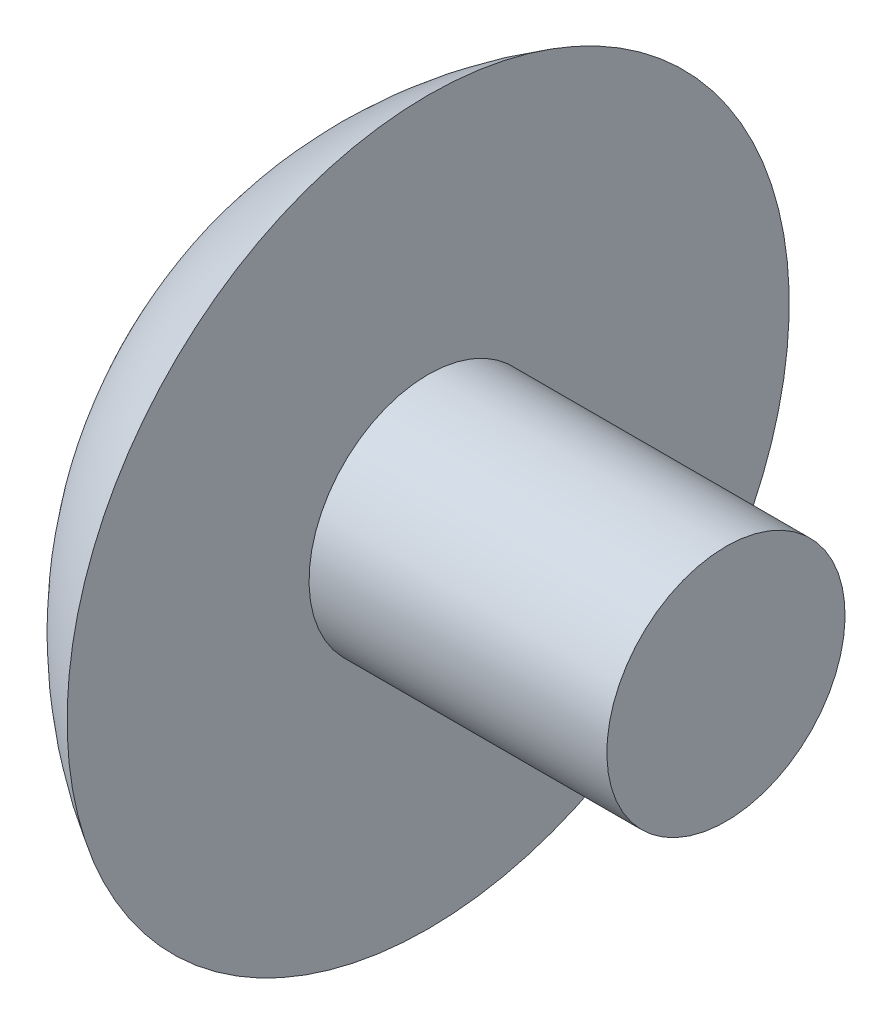
from build123d import *


with BuildPart() as part:
    # Esquisse5 → Révolution2 (revolve)
    with BuildSketch(Plane.XY):
        with BuildLine():
            Line((0, 0), (-8.5, 0))
            ThreePointArc((-8.5, 0), (-7.562177826, -3.5), (-5, -6.062177826))
            Line((-5, -6.062177826), (-5, -2))
            Line((-5, -2), (0, -2))
            Line((0, -2), (0, 0))
        make_face()
    revolve(axis=Axis((0, 0, 0), (-1, 0, 0)))


solid = part.part
